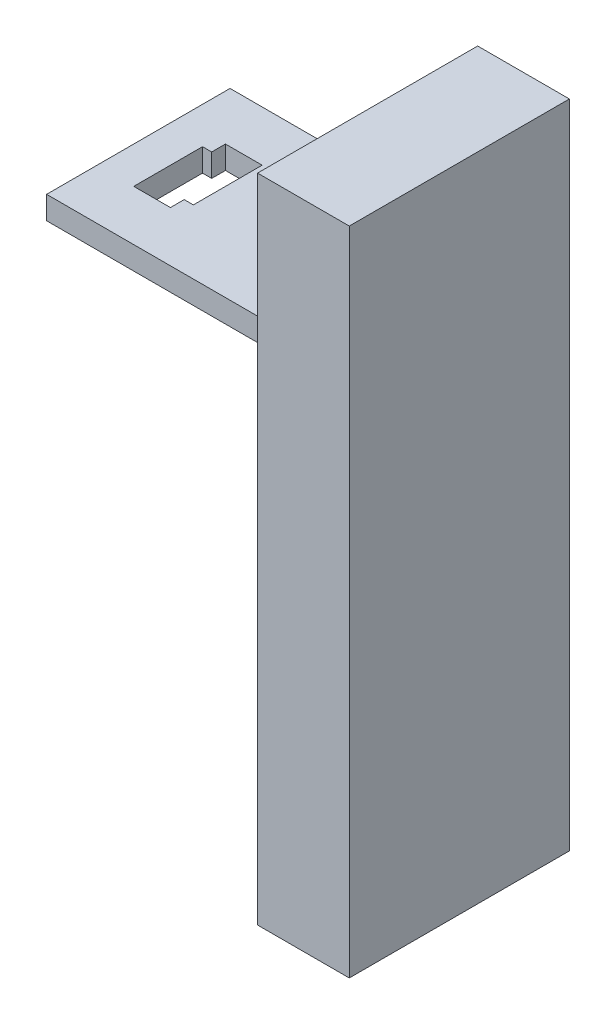
from build123d import *

# Parameters (mm, degrees)
SKETCH2_W                = 142.009514535
SKETCH2_H                = 48
BOSS_EXTRUDE1_DEPTH      = 20
SKETCH3_R                = 2.6
CUT_EXTRUDE1_DEPTH       = 16
SKETCH4_W                = 5
SKETCH4_H                = 40
BOSS_EXTRUDE2_DEPTH      = 50
BOSS_EXTRUDE2_DEPTH_BACK = 2
CUT_EXTRUDE2_DEPTH       = 5
SKETCH8_W                = 5.2
SKETCH8_H                = 41
CUT_EXTRUDE3_DEPTH       = 2


with BuildPart() as part:
    # Sketch2 → Boss-Extrude1 (new body)
    with BuildSketch(Plane.YZ):
        with Locations((39.504757268, 0)):
            Rectangle(SKETCH2_W, SKETCH2_H)
    extrude(amount=BOSS_EXTRUDE1_DEPTH)

    # Sketch3 → Cut-Extrude1 (cut)
    with BuildSketch(Plane(origin=(0, 0, 0), x_dir=(0, -1, 0), z_dir=(-1, 0, 0))):
        with Locations((-14, 13)):
            Circle(SKETCH3_R)
        with Locations((13.976189248, 13)):
            Circle(SKETCH3_R)
        with Locations((13.976189248, -13)):
            Circle(SKETCH3_R)
        with Locations((-14, -13)):
            Circle(SKETCH3_R)
    extrude(amount=-CUT_EXTRUDE1_DEPTH, mode=Mode.SUBTRACT)

    # Sketch4 → Boss-Extrude2 (add, two sides)
    with BuildSketch(Plane(origin=(0, 0, 0), x_dir=(0, -1, 0), z_dir=(-1, 0, 0))) as boss_extrude2_sk:
        with Locations((-77, 0)):
            Rectangle(SKETCH4_W, SKETCH4_H)
    extrude(amount=BOSS_EXTRUDE2_DEPTH)
    extrude(boss_extrude2_sk.sketch, amount=-BOSS_EXTRUDE2_DEPTH_BACK)

    # Sketch5 → Cut-Extrude2 (cut)
    with BuildSketch(Plane(origin=(0, 79.5, 0), x_dir=(-1, 0, 0), z_dir=(0, 1, 0))):
        Polygon((32, -9), (40, -9), (40, -6), (42, -6), (42, 9), (34, 9), (34, 6), (32, 6), align=None)
    extrude(amount=-CUT_EXTRUDE2_DEPTH, mode=Mode.SUBTRACT)


with BuildPart() as body_2:
    # Split1: the piece on the far side of the plane
    add(part.part)
    split(bisect_by=Plane(origin=(0, 0, 0), x_dir=(0, 0, -1), z_dir=(-1, 0, 0)), keep=Keep.BOTTOM)

    # Sketch8 → Cut-Extrude3 (cut)
    with BuildSketch(Plane(origin=(0, 0, 0), x_dir=(0, -1, 0), z_dir=(-1, 0, 0))):
        with Locations((-77.2, 0)):
            Rectangle(SKETCH8_W, SKETCH8_H)
    extrude(amount=-CUT_EXTRUDE3_DEPTH, mode=Mode.SUBTRACT)


with BuildPart() as part_1:
    add(part.part)

    # Split1
    split(bisect_by=Plane(origin=(0, 0, 0), x_dir=(0, 0, -1), z_dir=(-1, 0, 0)), keep=Keep.TOP)


solid = Compound([body_2.part, part_1.part])
